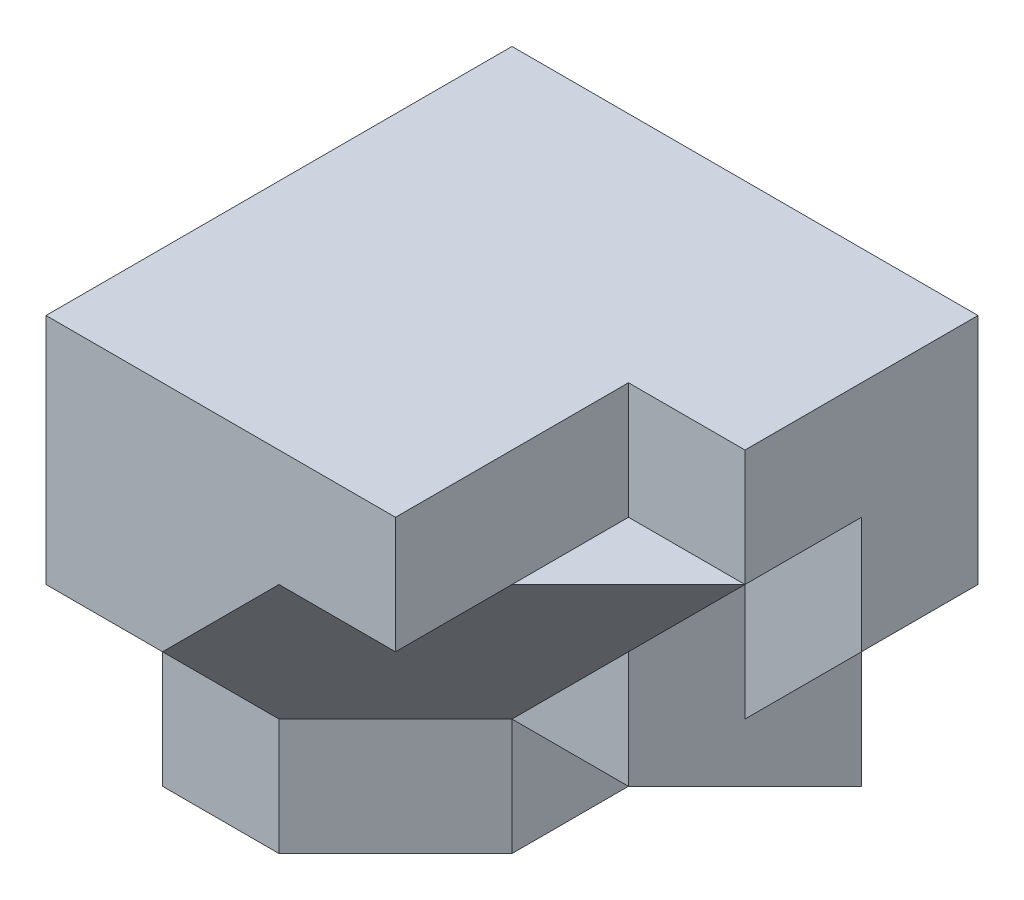
from build123d import *

# Parameters (mm, degrees)
SKETCH1_W            = 40
SKETCH1_H            = 40
BOSS_EXTRUDE1_DEPTH  = 20
CUT_EXTRUDE1_DEPTH   = 20
BOSS_EXTRUDE2_DEPTH  = 10
BOSS_EXTRUDE3_DEPTH  = 10
SKETCH5_W            = 10
SKETCH5_H            = 12.477634561
BOSS_EXTRUDE4_DEPTH  = 20
BOSS_EXTRUDE5_DEPTH  = 10
SKETCH7_W            = 30
SKETCH7_H            = 10
BOSS_EXTRUDE6_DEPTH  = 20
BOSS_EXTRUDE7_DEPTH  = 10
BOSS_EXTRUDE8_DEPTH  = 20
SKETCH13_W           = 10
SKETCH13_H           = 10
BOSS_EXTRUDE10_DEPTH = 10
BOSS_EXTRUDE13_DEPTH = 10
SKETCH15_W           = 20
SKETCH15_H           = 30.380258446
BOSS_EXTRUDE15_DEPTH = 30
CUT_EXTRUDE2_DEPTH   = 30
CUT_EXTRUDE3_DEPTH   = 30
CUT_EXTRUDE4_DEPTH   = 30
CUT_EXTRUDE5_DEPTH   = 30
BOSS_EXTRUDE16_DEPTH = 10
CUT_EXTRUDE6_DEPTH   = 10
SKETCH25_W           = 10
SKETCH25_H           = 10
CUT_EXTRUDE7_DEPTH   = 10


with BuildPart() as part:
    # Sketch1 → Boss-Extrude1 (new body)
    with BuildSketch(Plane.XY):
        with Locations((20, 20)):
            Rectangle(SKETCH1_W, SKETCH1_H)
    extrude(amount=BOSS_EXTRUDE1_DEPTH)

    # Sketch2 → Cut-Extrude1 (cut)
    with BuildSketch(Plane.XY.offset(20)):
        Polygon((20, 10), (20, 0), (40, 0), (40, 30), align=None)
    extrude(amount=-CUT_EXTRUDE1_DEPTH, mode=Mode.SUBTRACT)

    # Sketch3 → Boss-Extrude2 (add)
    with BuildSketch(Plane.XZ):
        Polygon((20, 20), (0, 20), (0, 30), (10, 30), align=None)
    extrude(amount=-BOSS_EXTRUDE2_DEPTH)

    # Sketch4 → Boss-Extrude3 (add)
    with BuildSketch(Plane(origin=(20, 0, 0), x_dir=(0, 0, -1), z_dir=(1, 0, 0))):
        Polygon((0, 0), (-20, 10), (0, 10), align=None)
    extrude(amount=BOSS_EXTRUDE3_DEPTH)

    # Sketch5 → Boss-Extrude4 (add)
    with BuildSketch(Plane.XY.offset(20)):
        with Locations((25, 16.238817281)):
            Rectangle(SKETCH5_W, SKETCH5_H)
    extrude(amount=-BOSS_EXTRUDE4_DEPTH)

    # Sketch6 → Boss-Extrude5 (add)
    with BuildSketch(Plane(origin=(0, 0, 0), x_dir=(-1, 0, 0), z_dir=(0, 0, -1))):
        Polygon((-30, 10), (-40, 20), (-40, 30), (-30, 20), align=None)
    extrude(amount=-BOSS_EXTRUDE5_DEPTH)

    # Sketch7 → Boss-Extrude6 (add)
    with BuildSketch(Plane.XY.offset(20)):
        with Locations((15, 35)):
            Rectangle(SKETCH7_W, SKETCH7_H)
    extrude(amount=BOSS_EXTRUDE6_DEPTH)

    # Sketch8 → Boss-Extrude7 (add)
    with BuildSketch(Plane.ZY):
        Polygon((40, 30), (40, 20), (30, 10), (20, 10), (20, 30), align=None)
    extrude(amount=-BOSS_EXTRUDE7_DEPTH)

    # Sketch9 → Boss-Extrude8 (add)
    with BuildSketch(Plane.XY.offset(40)):
        Polygon((10, 20), (20, 30), (10, 30), align=None)
    extrude(amount=-BOSS_EXTRUDE8_DEPTH)

    # Sketch13 → Boss-Extrude10 (add)
    with BuildSketch(Plane(origin=(0, 40, 0), x_dir=(1, 0, 0), z_dir=(0, 1, 0))):
        with Locations((35, -25)):
            Rectangle(SKETCH13_W, SKETCH13_H)
    extrude(amount=-BOSS_EXTRUDE10_DEPTH)

    # Sketch12 → Boss-Extrude13 (add)
    with BuildSketch(Plane(origin=(10, -10, 10), x_dir=(-0.816496581, -0.40824829, 0.40824829), z_dir=(-0.577350269, 0.577350269, -0.577350269))):
        Polygon((-12.247448714, 21.213203436), (0, 42.426406871), (-12.247448714, 49.497474683), (-24.494897428, 28.284271247), align=None)
    extrude(amount=BOSS_EXTRUDE13_DEPTH)

    # Sketch15 → Boss-Extrude15 (add)
    with BuildSketch(Plane(origin=(0, 40, 0), x_dir=(1, 0, 0), z_dir=(0, 1, 0))):
        with Locations((10, -24.809870777)):
            Rectangle(SKETCH15_W, SKETCH15_H)
    extrude(amount=-BOSS_EXTRUDE15_DEPTH)

    # Sketch17 → Cut-Extrude2 (cut)
    with BuildSketch(Plane(origin=(10, -10, 10), x_dir=(-0.816496581, -0.40824829, 0.40824829), z_dir=(-0.577350269, 0.577350269, -0.577350269))):
        Polygon((-12.247448714, 49.497474683), (0, 42.426406871), (-12.247448714, 21.213203436), align=None)
    extrude(amount=-CUT_EXTRUDE2_DEPTH, mode=Mode.SUBTRACT)

    # Sketch18 → Cut-Extrude3 (cut)
    with BuildSketch(Plane(origin=(10, -10, 10), x_dir=(-0.816496581, -0.40824829, 0.40824829), z_dir=(-0.577350269, 0.577350269, -0.577350269))):
        Polygon((0, 42.426406871), (0, 28.284271247), (-12.247448714, 21.213203436), align=None)
    extrude(amount=-CUT_EXTRUDE3_DEPTH, mode=Mode.SUBTRACT)

    # Sketch20 → Cut-Extrude4 (cut)
    with BuildSketch(Plane(origin=(0, 0, 0), x_dir=(-0.365148372, -0.182574186, -0.912870929), z_dir=(0.816496581, 0.40824829, -0.40824829))):
        Polygon((-32.86335345, 4.472135955), (-43.8178046, 2.236067977), (-43.8178046, 13.416407865), align=None)
    extrude(amount=-CUT_EXTRUDE4_DEPTH, mode=Mode.SUBTRACT)

    # Sketch21 → Cut-Extrude5 (cut)
    with BuildSketch(Plane.ZY):
        Polygon((30, 10), (40, 20), (40, 10), align=None)
    extrude(amount=-CUT_EXTRUDE5_DEPTH, mode=Mode.SUBTRACT)

    # Sketch23 → Boss-Extrude16 (add)
    with BuildSketch(Plane(origin=(10, -10, 10), x_dir=(-0.816496581, -0.40824829, 0.40824829), z_dir=(-0.577350269, 0.577350269, -0.577350269))):
        Polygon((-12.247448714, 49.497474683), (-24.494897428, 28.284271247), (-36.742346142, 35.355339059), align=None)
    extrude(amount=BOSS_EXTRUDE16_DEPTH)

    # Sketch24 → Cut-Extrude6 (cut)
    with BuildSketch(Plane(origin=(0, 40, 0), x_dir=(1, 0, 0), z_dir=(0, 1, 0))):
        Polygon((30, -30), (40, -20), (40, -30), align=None)
    extrude(amount=-CUT_EXTRUDE6_DEPTH, mode=Mode.SUBTRACT)

    # Sketch25 → Cut-Extrude7 (cut)
    with BuildSketch(Plane(origin=(0, 40, 0), x_dir=(1, 0, 0), z_dir=(0, 1, 0))):
        with Locations((35, -25)):
            Rectangle(SKETCH25_W, SKETCH25_H)
    extrude(amount=-CUT_EXTRUDE7_DEPTH, mode=Mode.SUBTRACT)


solid = part.part
